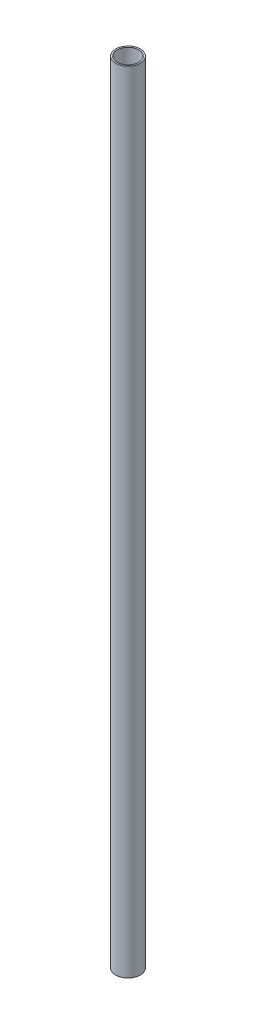
from build123d import *

# Parameters (mm, degrees)
SKETCH1_R      = 12.7
SKETCH1_R_2    = 11.1125
EXTRUDE1_DEPTH = 406.4


with BuildPart() as part:
    # Sketch1 → Extrude1 (new body, symmetric)
    with BuildSketch(Plane(origin=(0, 0, 0), x_dir=(1, 0, 0), z_dir=(0, 1, 0))):
        Circle(SKETCH1_R)
        Circle(SKETCH1_R_2, mode=Mode.SUBTRACT)
    extrude(amount=EXTRUDE1_DEPTH, both=True)


solid = part.part
